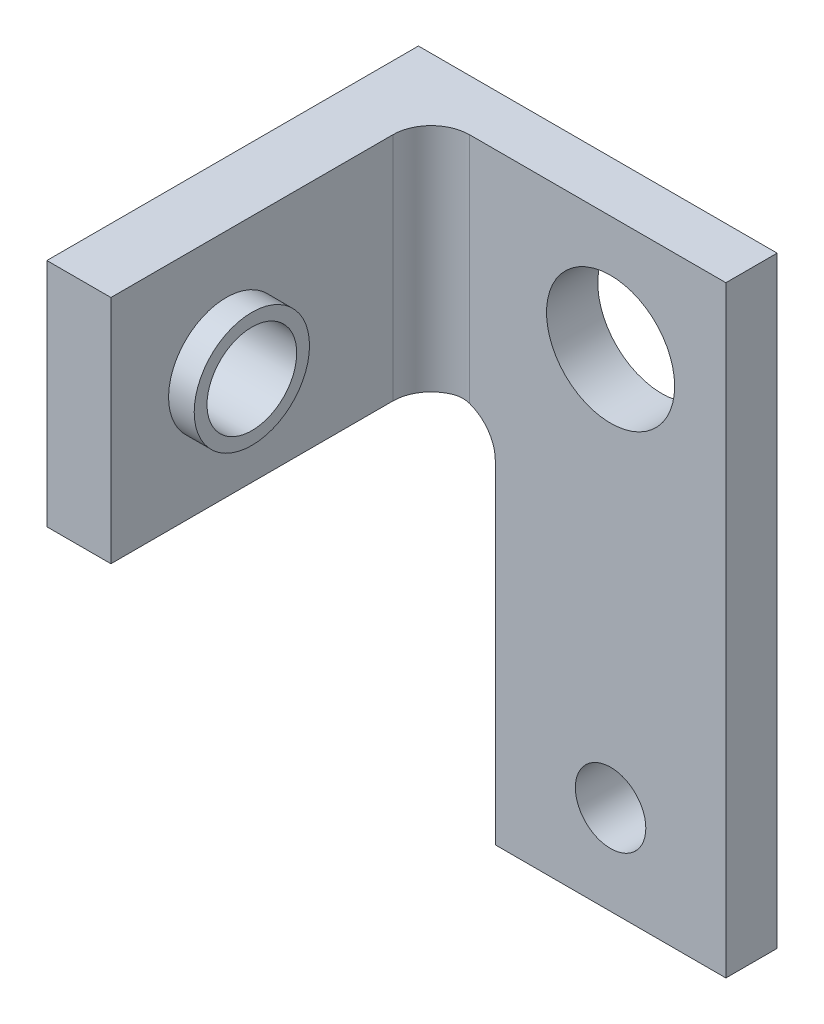
from build123d import *

# Parameters (mm, degrees)
SKETCH1_W           = 9
SKETCH1_H           = 22
BOSS_EXTRUDE1_DEPTH = 2
SKETCH2_R           = 2.5
SKETCH2_R_2         = 1.375
CUT_EXTRUDE1_DEPTH  = 2
SKETCH3_W           = 2
SKETCH3_H           = 9
BOSS_EXTRUDE2_DEPTH = 5
SKETCH5_W           = 2.5
SKETCH5_H           = 9
BOSS_EXTRUDE4_DEPTH = 12.5
SKETCH6_R           = 1.75
CUT_EXTRUDE2_DEPTH  = 2.5
SKETCH7_R           = 2.25
BOSS_EXTRUDE5_DEPTH = 1
SKETCH8_R           = 1.75
CUT_EXTRUDE3_DEPTH  = 1
SKETCH9_R           = 2.25
BOSS_EXTRUDE6_DEPTH = 1
SKETCH10_R          = 1.75
CUT_EXTRUDE4_DEPTH  = 1
FILLET1_R           = 1.5
FILLET2_R           = 1.5
SKETCH11_W          = 9
SKETCH11_H          = 2
BOSS_EXTRUDE7_DEPTH = 1.5


with BuildPart() as part:
    # Sketch1 → Boss-Extrude1 (new body)
    with BuildSketch(Plane.XY):
        Rectangle(SKETCH1_W, SKETCH1_H)
    extrude(amount=BOSS_EXTRUDE1_DEPTH)

    # Sketch2 → Cut-Extrude1 (cut)
    with BuildSketch(Plane.XY.offset(2)):
        with Locations((0, 6.5)):
            Circle(SKETCH2_R)
        with Locations((0, -9)):
            Circle(SKETCH2_R_2)
    extrude(amount=-CUT_EXTRUDE1_DEPTH, mode=Mode.SUBTRACT)

    # Sketch3 → Boss-Extrude2 (add)
    with BuildSketch(Plane.ZY.offset(4.5)):
        with Locations((1, 6.5)):
            Rectangle(SKETCH3_W, SKETCH3_H)
    extrude(amount=BOSS_EXTRUDE2_DEPTH)

    # Sketch5 → Boss-Extrude4 (add)
    with BuildSketch(Plane.XY.offset(2)):
        with Locations((-8.25, 6.5)):
            Rectangle(SKETCH5_W, SKETCH5_H)
    extrude(amount=BOSS_EXTRUDE4_DEPTH)

    # Sketch6 → Cut-Extrude2 (cut)
    with BuildSketch(Plane(origin=(-7, 0, 0), x_dir=(0, 0, -1), z_dir=(1, 0, 0))):
        with Locations((-10, 6.5)):
            Circle(SKETCH6_R)
    extrude(amount=-CUT_EXTRUDE2_DEPTH, mode=Mode.SUBTRACT)

    # Sketch7 → Boss-Extrude5 (add)
    with BuildSketch(Plane(origin=(-7, 0, 0), x_dir=(0, 0, -1), z_dir=(1, 0, 0))):
        with Locations((-10, 6.5)):
            Circle(SKETCH7_R)
    extrude(amount=BOSS_EXTRUDE5_DEPTH)

    # Sketch8 → Cut-Extrude3 (cut)
    with BuildSketch(Plane(origin=(-6, 0, 0), x_dir=(0, 0, -1), z_dir=(1, 0, 0))):
        with Locations((-10, 6.5)):
            Circle(SKETCH8_R)
    extrude(amount=-CUT_EXTRUDE3_DEPTH, mode=Mode.SUBTRACT)

    # Sketch9 → Boss-Extrude6 (add)
    with BuildSketch(Plane.ZY.offset(9.5)):
        with Locations((10, 6.5)):
            Circle(SKETCH9_R)
    extrude(amount=BOSS_EXTRUDE6_DEPTH)

    # Sketch10 → Cut-Extrude4 (cut)
    with BuildSketch(Plane.ZY.offset(10.5)):
        with Locations((10, 6.5)):
            Circle(SKETCH10_R)
    extrude(amount=-CUT_EXTRUDE4_DEPTH, mode=Mode.SUBTRACT)

    # Fillet1
    fillet1_edges = [part.edges().sort_by_distance(p)[0] for p in [
        (-7, 6.5, 2),
    ]]
    fillet(fillet1_edges, radius=FILLET1_R)

    # Fillet2
    fillet2_edges = [part.edges().sort_by_distance(p)[0] for p in [
        (-4.5, 2, 1),
    ]]
    fillet(fillet2_edges, radius=FILLET2_R)

    # Sketch11 → Boss-Extrude7 (add)
    with BuildSketch(Plane.XZ.offset(11)):
        with Locations((0, 1)):
            Rectangle(SKETCH11_W, SKETCH11_H)
    extrude(amount=BOSS_EXTRUDE7_DEPTH)


solid = part.part
